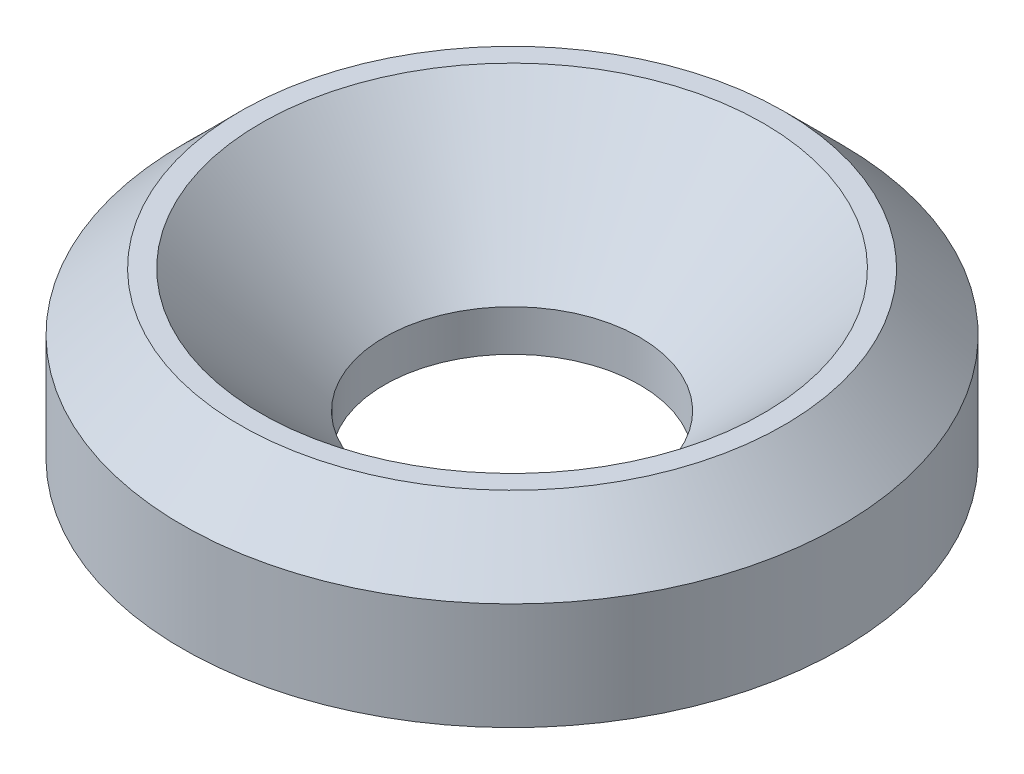
from build123d import *


with BuildPart() as part:
    # Sketch1 → Revolve1 (revolve)
    with BuildSketch(Plane.XY):
        Polygon((4, 0), (4, 1.3), (3.3, 2), (3.05, 2), (1.55, 0.5), (1.55, 0), align=None)
    revolve(axis=Axis((0, 0, 0), (0, 1, 0)))


solid = part.part
